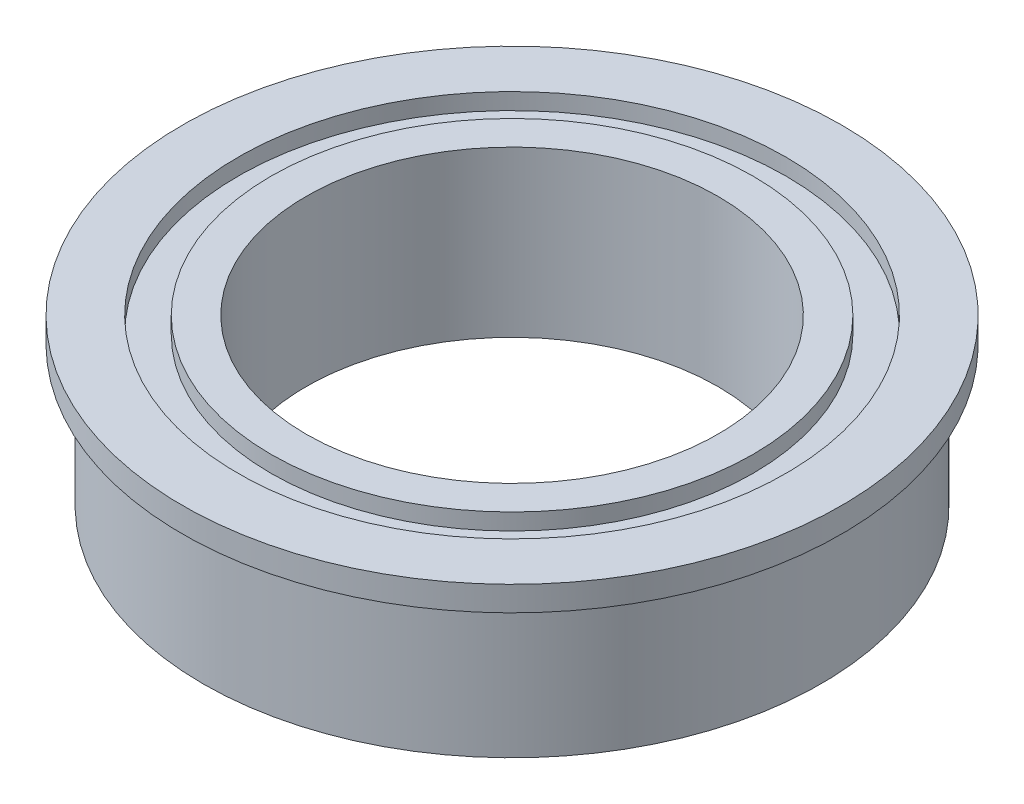
from build123d import *


with BuildPart() as part:
    # Sketch1 → Revolve1 (revolve)
    with BuildSketch(Plane.XY):
        Polygon((5, 0.6), (5, -3.4), (5.85, -3.4), (5.85, -3), (6.65, -3), (6.65, -3.4), (7.5, -3.4), (7.5, 0), (8, 0), (8, 0.6), (6.65, 0.6), (6.65, 0.2), (5.85, 0.2), (5.85, 0.6), align=None)
    revolve(axis=Axis((0, 0, 0), (0, 1, 0)))


solid = part.part
